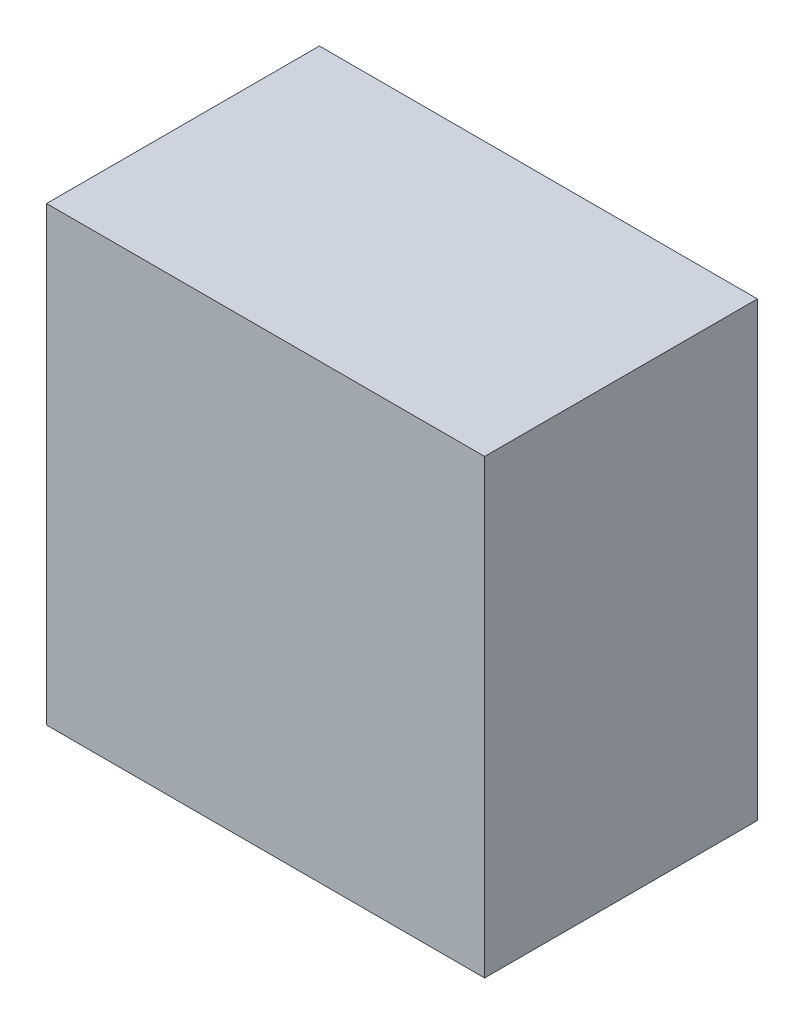
from build123d import *

# Parameters (mm, degrees)
SKETCH2_W           = 144.5
SKETCH2_H           = 149
BOSS_EXTRUDE2_DEPTH = 90


with BuildPart() as part:
    # Sketch2 → Boss-Extrude2 (new body)
    with BuildSketch(Plane.XY):
        Rectangle(SKETCH2_W, SKETCH2_H)
    extrude(amount=BOSS_EXTRUDE2_DEPTH)


solid = part.part
